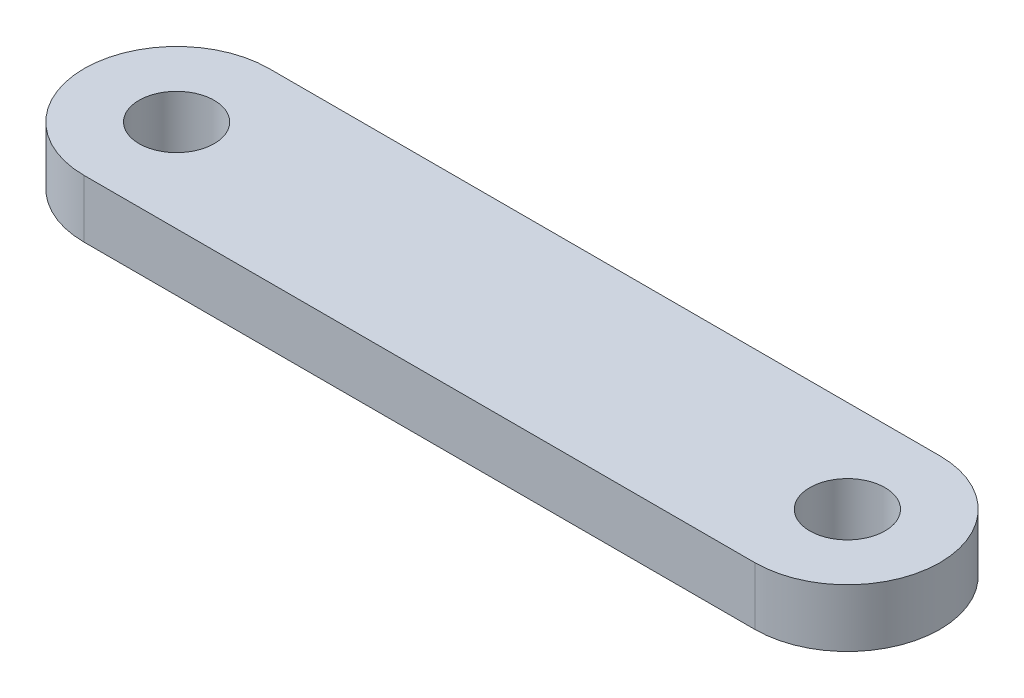
from build123d import *

# Parameters (mm, degrees)
BOSS_EXTRUDE1_DEPTH = 2.5
SKETCH2_R           = 1.625
CUT_EXTRUDE1_DEPTH  = 2.5


with BuildPart() as part:
    # Sketch1 → Boss-Extrude1 (new body)
    with BuildSketch(Plane(origin=(0, 0, 0), x_dir=(1, 0, 0), z_dir=(0, 1, 0))):
        with BuildLine():
            Line((0, 4), (29, 4))
            ThreePointArc((29, 4), (33, 0), (29, -4))
            Line((29, -4), (0, -4))
            ThreePointArc((0, -4), (-4, 0), (0, 4))
        make_face()
    extrude(amount=BOSS_EXTRUDE1_DEPTH)

    # Sketch2 → Cut-Extrude1 (cut)
    with BuildSketch(Plane(origin=(0, 2.5, 0), x_dir=(1, 0, 0), z_dir=(0, 1, 0))):
        Circle(SKETCH2_R)
        with Locations((29, 0)):
            Circle(SKETCH2_R)
    extrude(amount=-CUT_EXTRUDE1_DEPTH, mode=Mode.SUBTRACT)


solid = part.part
